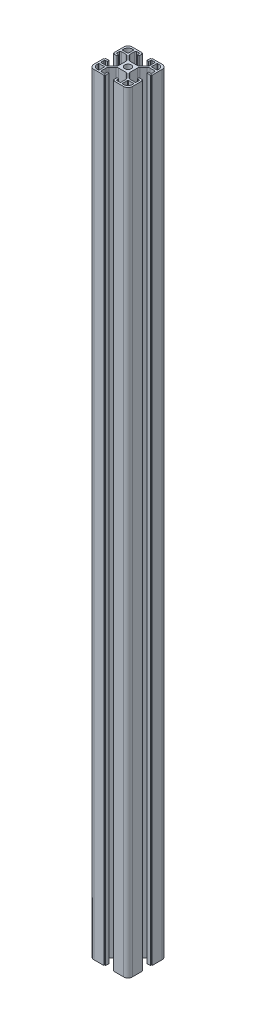
from build123d import *

# Parameters (mm, degrees)
BOSS_EXTRUDE2_DEPTH = 800


with BuildPart() as part:
    # Sketch1 → Boss-Extrude2 (new body)
    with BuildSketch(Plane(origin=(0, 0, 0), x_dir=(1, 0, 0), z_dir=(0, 1, 0))):
        with BuildLine():
            Line((84.170223908, 31.720417041), (84.170223908, 42.120417041))
            Line((84.170223908, 42.120417041), (83.570223908, 42.120417041))
            ThreePointArc((83.570223908, 42.120417041), (83.428802552, 42.178995685), (83.370223908, 42.320417041))
            Line((83.370223908, 42.320417041), (83.370223908, 42.920417041))
            ThreePointArc((83.370223908, 42.920417041), (83.311645264, 43.061838398), (83.170223908, 43.120417041))
            Line((83.170223908, 43.120417041), (79.670223908, 43.120417041))
            Line((79.670223908, 43.120417041), (79.670223908, 41.320417041))
            Line((79.670223908, 41.320417041), (81.370223908, 41.320417041))
            ThreePointArc((81.370223908, 41.320417041), (82.077330689, 41.027523823), (82.370223908, 40.320417041))
            Line((82.370223908, 40.320417041), (82.370223908, 37.970417041))
            ThreePointArc((82.370223908, 37.970417041), (82.077330689, 37.26331026), (81.370223908, 36.970417041))
            Line((81.370223908, 36.970417041), (76.723524767, 36.970417041))
            ThreePointArc((76.723524767, 36.970417041), (75.57547447, 37.198778444), (74.602204423, 37.849096698))
            Line((74.602204423, 37.849096698), (71.048903564, 41.402397557))
            ThreePointArc((71.048903564, 41.402397557), (70.39858531, 42.375667603), (70.170223908, 43.5237179))
            Line((70.170223908, 43.5237179), (70.170223908, 50.917116183))
            ThreePointArc((70.170223908, 50.917116183), (70.39858531, 52.06516648), (71.048903564, 53.038436526))
            Line((71.048903564, 53.038436526), (74.602204423, 56.591737385))
            ThreePointArc((74.602204423, 56.591737385), (75.57547447, 57.242055639), (76.723524767, 57.470417041))
            Line((76.723524767, 57.470417041), (81.370223908, 57.470417041))
            ThreePointArc((81.370223908, 57.470417041), (82.077330689, 57.177523823), (82.370223908, 56.470417041))
            Line((82.370223908, 56.470417041), (82.370223908, 54.120417041))
            ThreePointArc((82.370223908, 54.120417041), (82.077330689, 53.41331026), (81.370223908, 53.120417041))
            Line((81.370223908, 53.120417041), (79.670223908, 53.120417041))
            Line((79.670223908, 53.120417041), (79.670223908, 51.320417041))
            Line((79.670223908, 51.320417041), (83.170223908, 51.320417041))
            ThreePointArc((83.170223908, 51.320417041), (83.311645264, 51.378995685), (83.370223908, 51.520417041))
            Line((83.370223908, 51.520417041), (83.370223908, 52.120417041))
            ThreePointArc((83.370223908, 52.120417041), (83.428802552, 52.261838398), (83.570223908, 52.320417041))
            Line((83.570223908, 52.320417041), (84.170223908, 52.320417041))
            Line((84.170223908, 52.320417041), (84.170223908, 62.720417041))
            ThreePointArc((84.170223908, 62.720417041), (82.852204423, 65.902397557), (79.670223908, 67.220417041))
            Line((79.670223908, 67.220417041), (69.270223908, 67.220417041))
            Line((69.270223908, 67.220417041), (69.270223908, 66.420417041))
            Line((69.270223908, 66.420417041), (68.470223908, 66.420417041))
            ThreePointArc((68.470223908, 66.420417041), (68.328802552, 66.361838398), (68.270223908, 66.220417041))
            Line((68.270223908, 66.220417041), (68.270223908, 62.720417041))
            Line((68.270223908, 62.720417041), (70.070223908, 62.720417041))
            Line((70.070223908, 62.720417041), (70.070223908, 64.420417041))
            ThreePointArc((70.070223908, 64.420417041), (70.363117127, 65.127523823), (71.070223908, 65.420417041))
            Line((71.070223908, 65.420417041), (73.420223908, 65.420417041))
            ThreePointArc((73.420223908, 65.420417041), (74.127330689, 65.127523823), (74.420223908, 64.420417041))
            Line((74.420223908, 64.420417041), (74.420223908, 59.7737179))
            ThreePointArc((74.420223908, 59.7737179), (74.191862505, 58.625667603), (73.541544251, 57.652397557))
            Line((73.541544251, 57.652397557), (69.988243393, 54.099096698))
            ThreePointArc((69.988243393, 54.099096698), (69.014973346, 53.448778444), (67.866923049, 53.220417041))
            Line((67.866923049, 53.220417041), (60.473524767, 53.220417041))
            ThreePointArc((60.473524767, 53.220417041), (59.32547447, 53.448778444), (58.352204423, 54.099096698))
            Line((58.352204423, 54.099096698), (54.798903564, 57.652397557))
            ThreePointArc((54.798903564, 57.652397557), (54.14858531, 58.625667603), (53.920223908, 59.7737179))
            Line((53.920223908, 59.7737179), (53.920223908, 64.420417041))
            ThreePointArc((53.920223908, 64.420417041), (54.213117127, 65.127523823), (54.920223908, 65.420417041))
            Line((54.920223908, 65.420417041), (57.270223908, 65.420417041))
            ThreePointArc((57.270223908, 65.420417041), (57.977330689, 65.127523823), (58.270223908, 64.420417041))
            Line((58.270223908, 64.420417041), (58.270223908, 62.720417041))
            Line((58.270223908, 62.720417041), (60.070223908, 62.720417041))
            Line((60.070223908, 62.720417041), (60.070223908, 66.420417041))
            Line((60.070223908, 66.420417041), (59.270223908, 66.420417041))
            ThreePointArc((59.270223908, 66.420417041), (59.128802552, 66.478995685), (59.070223908, 66.620417041))
            Line((59.070223908, 66.620417041), (59.070223908, 67.220417041))
            Line((59.070223908, 67.220417041), (48.670223908, 67.220417041))
            ThreePointArc((48.670223908, 67.220417041), (45.488243393, 65.902397557), (44.170223908, 62.720417041))
            Line((44.170223908, 62.720417041), (44.170223908, 52.320417041))
            Line((44.170223908, 52.320417041), (44.770223908, 52.320417041))
            ThreePointArc((44.770223908, 52.320417041), (44.911645264, 52.261838398), (44.970223908, 52.120417041))
            Line((44.970223908, 52.120417041), (44.970223908, 51.520417041))
            ThreePointArc((44.970223908, 51.520417041), (45.028802552, 51.378995685), (45.170223908, 51.320417041))
            Line((45.170223908, 51.320417041), (48.670223908, 51.320417041))
            Line((48.670223908, 51.320417041), (48.670223908, 53.120417041))
            Line((48.670223908, 53.120417041), (46.970223908, 53.120417041))
            ThreePointArc((46.970223908, 53.120417041), (46.263117127, 53.41331026), (45.970223908, 54.120417041))
            Line((45.970223908, 54.120417041), (45.970223908, 56.470417041))
            ThreePointArc((45.970223908, 56.470417041), (46.263117127, 57.177523823), (46.970223908, 57.470417041))
            Line((46.970223908, 57.470417041), (51.616923049, 57.470417041))
            ThreePointArc((51.616923049, 57.470417041), (52.764973346, 57.242055639), (53.738243393, 56.591737385))
            Line((53.738243393, 56.591737385), (57.291544251, 53.038436526))
            ThreePointArc((57.291544251, 53.038436526), (57.941862505, 52.06516648), (58.170223908, 50.917116183))
            Line((58.170223908, 50.917116183), (58.170223908, 43.5237179))
            ThreePointArc((58.170223908, 43.5237179), (57.941862505, 42.375667603), (57.291544251, 41.402397557))
            Line((57.291544251, 41.402397557), (53.738243393, 37.849096698))
            ThreePointArc((53.738243393, 37.849096698), (52.764973346, 37.198778444), (51.616923049, 36.970417041))
            Line((51.616923049, 36.970417041), (46.970223908, 36.970417041))
            ThreePointArc((46.970223908, 36.970417041), (46.263117127, 37.26331026), (45.970223908, 37.970417041))
            Line((45.970223908, 37.970417041), (45.970223908, 40.320417041))
            ThreePointArc((45.970223908, 40.320417041), (46.263117127, 41.027523823), (46.970223908, 41.320417041))
            Line((46.970223908, 41.320417041), (48.670223908, 41.320417041))
            Line((48.670223908, 41.320417041), (48.670223908, 43.120417041))
            Line((48.670223908, 43.120417041), (45.170223908, 43.120417041))
            ThreePointArc((45.170223908, 43.120417041), (45.028802552, 43.061838398), (44.970223908, 42.920417041))
            Line((44.970223908, 42.920417041), (44.970223908, 42.320417041))
            ThreePointArc((44.970223908, 42.320417041), (44.911645264, 42.178995685), (44.770223908, 42.120417041))
            Line((44.770223908, 42.120417041), (44.170223908, 42.120417041))
            Line((44.170223908, 42.120417041), (44.170223908, 31.720417041))
            ThreePointArc((44.170223908, 31.720417041), (45.488243393, 28.538436526), (48.670223908, 27.220417041))
            Line((48.670223908, 27.220417041), (59.070223908, 27.220417041))
            Line((59.070223908, 27.220417041), (59.070223908, 27.820417041))
            ThreePointArc((59.070223908, 27.820417041), (59.128802552, 27.961838398), (59.270223908, 28.020417041))
            Line((59.270223908, 28.020417041), (59.870223908, 28.020417041))
            ThreePointArc((59.870223908, 28.020417041), (60.011645264, 28.078995685), (60.070223908, 28.220417041))
            Line((60.070223908, 28.220417041), (60.070223908, 31.720417041))
            Line((60.070223908, 31.720417041), (58.270223908, 31.720417041))
            Line((58.270223908, 31.720417041), (58.270223908, 30.020417041))
            ThreePointArc((58.270223908, 30.020417041), (57.977330689, 29.31331026), (57.270223908, 29.020417041))
            Line((57.270223908, 29.020417041), (54.920223908, 29.020417041))
            ThreePointArc((54.920223908, 29.020417041), (54.213117127, 29.31331026), (53.920223908, 30.020417041))
            Line((53.920223908, 30.020417041), (53.920223908, 34.667116183))
            ThreePointArc((53.920223908, 34.667116183), (54.14858531, 35.81516648), (54.798903564, 36.788436526))
            Line((54.798903564, 36.788436526), (58.352204423, 40.341737385))
            ThreePointArc((58.352204423, 40.341737385), (59.32547447, 40.992055639), (60.473524767, 41.220417041))
            Line((60.473524767, 41.220417041), (67.866923049, 41.220417041))
            ThreePointArc((67.866923049, 41.220417041), (69.014973346, 40.992055639), (69.988243393, 40.341737385))
            Line((69.988243393, 40.341737385), (73.541544251, 36.788436526))
            ThreePointArc((73.541544251, 36.788436526), (74.191862505, 35.81516648), (74.420223908, 34.667116183))
            Line((74.420223908, 34.667116183), (74.420223908, 30.020417041))
            ThreePointArc((74.420223908, 30.020417041), (74.127330689, 29.31331026), (73.420223908, 29.020417041))
            Line((73.420223908, 29.020417041), (71.070223908, 29.020417041))
            ThreePointArc((71.070223908, 29.020417041), (70.363117127, 29.31331026), (70.070223908, 30.020417041))
            Line((70.070223908, 30.020417041), (70.070223908, 31.720417041))
            Line((70.070223908, 31.720417041), (68.270223908, 31.720417041))
            Line((68.270223908, 31.720417041), (68.270223908, 28.220417041))
            ThreePointArc((68.270223908, 28.220417041), (68.328802552, 28.078995685), (68.470223908, 28.020417041))
            Line((68.470223908, 28.020417041), (69.070223908, 28.020417041))
            ThreePointArc((69.070223908, 28.020417041), (69.211645264, 27.961838398), (69.270223908, 27.820417041))
            Line((69.270223908, 27.820417041), (69.270223908, 27.220417041))
            Line((69.270223908, 27.220417041), (79.670223908, 27.220417041))
            ThreePointArc((79.670223908, 27.220417041), (82.852204423, 28.538436526), (84.170223908, 31.720417041))
        make_face()
        with BuildLine():
            Line((82.370223908, 34.670417041), (82.370223908, 33.520417041))
            ThreePointArc((82.370223908, 33.520417041), (81.052204423, 30.338436526), (77.870223908, 29.020417041))
            Line((77.870223908, 29.020417041), (76.720223908, 29.020417041))
            ThreePointArc((76.720223908, 29.020417041), (76.366670517, 29.166863651), (76.220223908, 29.520417041))
            Line((76.220223908, 29.520417041), (76.220223908, 34.670417041))
            ThreePointArc((76.220223908, 34.670417041), (76.366670517, 35.023970432), (76.720223908, 35.170417041))
            Line((76.720223908, 35.170417041), (81.870223908, 35.170417041))
            ThreePointArc((81.870223908, 35.170417041), (82.223777298, 35.023970432), (82.370223908, 34.670417041))
        make_face(mode=Mode.SUBTRACT)
        with BuildLine():
            Line((51.620223908, 29.020417041), (50.470223908, 29.020417041))
            ThreePointArc((50.470223908, 29.020417041), (47.288243393, 30.338436526), (45.970223908, 33.520417041))
            Line((45.970223908, 33.520417041), (45.970223908, 34.670417041))
            ThreePointArc((45.970223908, 34.670417041), (46.116670517, 35.023970432), (46.470223908, 35.170417041))
            Line((46.470223908, 35.170417041), (51.620223908, 35.170417041))
            ThreePointArc((51.620223908, 35.170417041), (51.973777298, 35.023970432), (52.120223908, 34.670417041))
            Line((52.120223908, 34.670417041), (52.120223908, 29.520417041))
            ThreePointArc((52.120223908, 29.520417041), (51.973777298, 29.166863651), (51.620223908, 29.020417041))
        make_face(mode=Mode.SUBTRACT)
        with BuildLine():
            Line((45.970223908, 59.770417041), (45.970223908, 60.920417041))
            ThreePointArc((45.970223908, 60.920417041), (47.288243393, 64.102397557), (50.470223908, 65.420417041))
            Line((50.470223908, 65.420417041), (51.620223908, 65.420417041))
            ThreePointArc((51.620223908, 65.420417041), (51.973777298, 65.273970432), (52.120223908, 64.920417041))
            Line((52.120223908, 64.920417041), (52.120223908, 59.770417041))
            ThreePointArc((52.120223908, 59.770417041), (51.973777298, 59.416863651), (51.620223908, 59.270417041))
            Line((51.620223908, 59.270417041), (46.470223908, 59.270417041))
            ThreePointArc((46.470223908, 59.270417041), (46.116670517, 59.416863651), (45.970223908, 59.770417041))
        make_face(mode=Mode.SUBTRACT)
        with BuildLine():
            Line((76.720223908, 65.420417041), (77.870223908, 65.420417041))
            ThreePointArc((77.870223908, 65.420417041), (81.052204423, 64.102397557), (82.370223908, 60.920417041))
            Line((82.370223908, 60.920417041), (82.370223908, 59.770417041))
            ThreePointArc((82.370223908, 59.770417041), (82.223777298, 59.416863651), (81.870223908, 59.270417041))
            Line((81.870223908, 59.270417041), (76.720223908, 59.270417041))
            ThreePointArc((76.720223908, 59.270417041), (76.366670517, 59.416863651), (76.220223908, 59.770417041))
            Line((76.220223908, 59.770417041), (76.220223908, 64.920417041))
            ThreePointArc((76.220223908, 64.920417041), (76.366670517, 65.273970432), (76.720223908, 65.420417041))
        make_face(mode=Mode.SUBTRACT)
        with BuildLine():
            ThreePointArc((60.770223908, 47.220417041), (64.170223908, 43.820417041), (67.570223908, 47.220417041))
            ThreePointArc((67.570223908, 47.220417041), (64.170223908, 50.620417041), (60.770223908, 47.220417041))
        make_face(mode=Mode.SUBTRACT)
    extrude(amount=BOSS_EXTRUDE2_DEPTH)


solid = part.part
